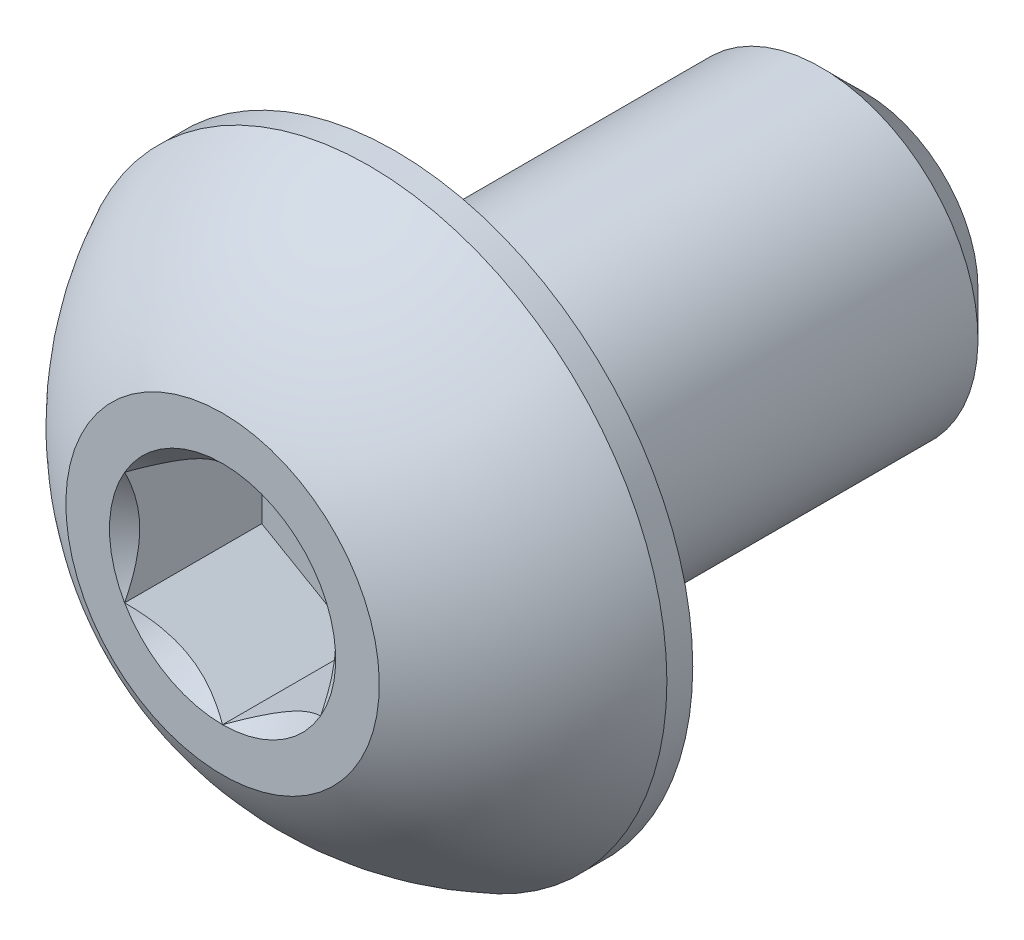
from build123d import *

# Parameters (mm, degrees)
CUT_EXTRUDE1_DEPTH = 1.75


with BuildPart() as part:
    # Sketch2 → Revolve1 (revolve)
    with BuildSketch(Plane(origin=(0, 0, 0), x_dir=(0, 0, -1), z_dir=(1, 0, 0)), mode=Mode.PRIVATE) as revolve1_sk:
        with BuildLine():
            Line((-4.1, 0), (4.1, 0))
            Line((4.1, 0), (4.1, 1.44))
            Line((4.1, 1.44), (3.54, 2))
            Line((3.54, 2), (-1.9, 2))
            Line((-1.9, 2), (-1.9, 3.8))
            Line((-1.9, 3.8), (-2.23, 3.8))
            ThreePointArc((-2.23, 3.8), (-3.306499853, 3.047002626), (-4.1, 2))
            Line((-4.1, 2), (-4.1, 0))
        make_face()
    revolve(revolve1_sk.sketch.rotate(Axis((0, 0, 4.1), (0, 0, -1)), 180), axis=Axis((0, 0, 4.1), (0, 0, -1)))

    # Sketch3 → Cut-Extrude1 (cut)
    with BuildSketch(Plane.XY.offset(4.1)):
        Polygon((0, 1.443375673), (-1.25, 0.721687836), (-1.25, -0.721687836), (0, -1.443375673), (1.25, -0.721687836), (1.25, 0.721687836), align=None)
    extrude(amount=-CUT_EXTRUDE1_DEPTH, mode=Mode.SUBTRACT)

    # Cut-Extrude2 cone 1 section (through the dimple's axis) → Cut-Extrude2 (revolve, cut)
    with BuildSketch(Plane(origin=(0, 0, 4.1), x_dir=(0, -1, 0), z_dir=(1, 0, 0))):
        Polygon((0, 0), (1.443375673, 0), (0, 1.443375673), align=None)
    revolve(axis=Axis((0, 0, 4.1), (0, 0, -1)), mode=Mode.SUBTRACT)


solid = part.part
